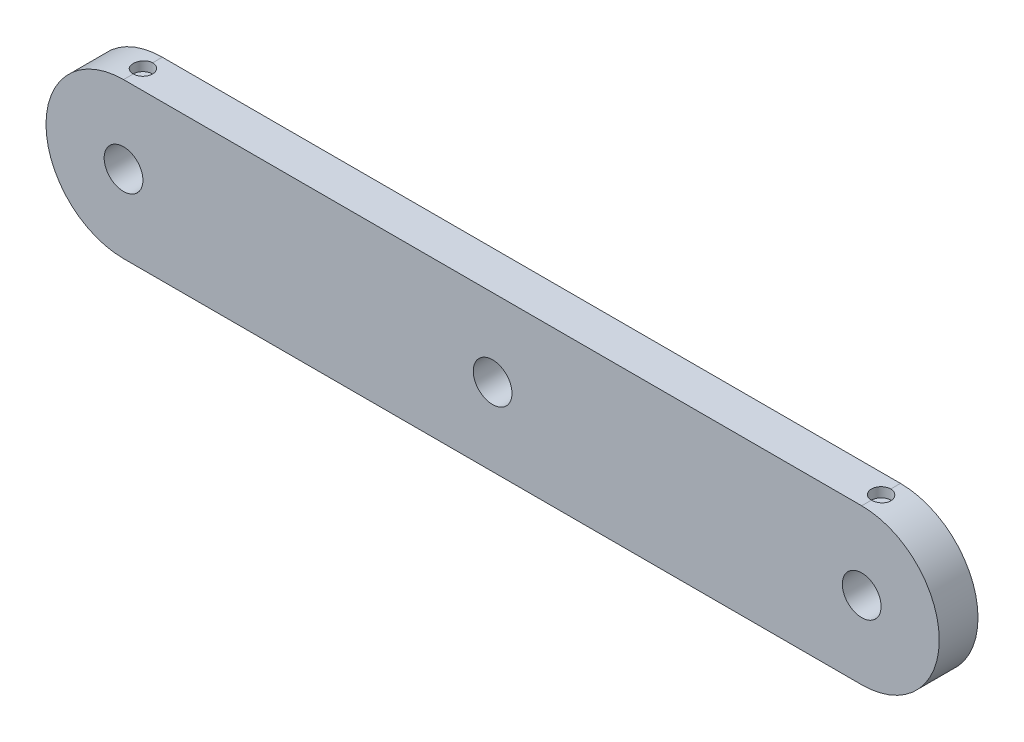
from build123d import *

# Parameters (mm, degrees)
SKETCH1_R           = 1
BOSS_EXTRUDE1_DEPTH = 2
SKETCH2_R           = 0.5
CUT_EXTRUDE1_DEPTH  = 0.5
SKETCH3_R           = 0.5
CUT_EXTRUDE2_DEPTH  = 0.5


with BuildPart() as part:
    # Sketch1 → Boss-Extrude1 (new body)
    with BuildSketch(Plane.XY):
        with BuildLine():
            Line((-19.041986571, 4), (19.041986571, 4))
            ThreePointArc((19.041986571, 4), (23.041986571, 0), (19.041986571, -4))
            Line((19.041986571, -4), (-19.041986571, -4))
            ThreePointArc((-19.041986571, -4), (-23.041986571, 0), (-19.041986571, 4))
        make_face()
        Circle(SKETCH1_R, mode=Mode.SUBTRACT)
        with Locations((19.041986571, 0)):
            Circle(SKETCH1_R, mode=Mode.SUBTRACT)
        with Locations((-19.041986571, 0)):
            Circle(SKETCH1_R, mode=Mode.SUBTRACT)
    extrude(amount=BOSS_EXTRUDE1_DEPTH)

    # Sketch2 → Cut-Extrude1 (cut)
    with BuildSketch(Plane(origin=(0, 4, 0), x_dir=(1, 0, 0), z_dir=(0, 1, 0))):
        with Locations((-19.041986571, -1)):
            Circle(SKETCH2_R)
        with Locations((19.041986571, -1)):
            Circle(SKETCH2_R)
    extrude(amount=-CUT_EXTRUDE1_DEPTH, mode=Mode.SUBTRACT)

    # Sketch3 → Cut-Extrude2 (cut)
    with BuildSketch(Plane.XZ.offset(4)):
        with Locations((0, 1)):
            Circle(SKETCH3_R)
    extrude(amount=-CUT_EXTRUDE2_DEPTH, mode=Mode.SUBTRACT)


solid = part.part
